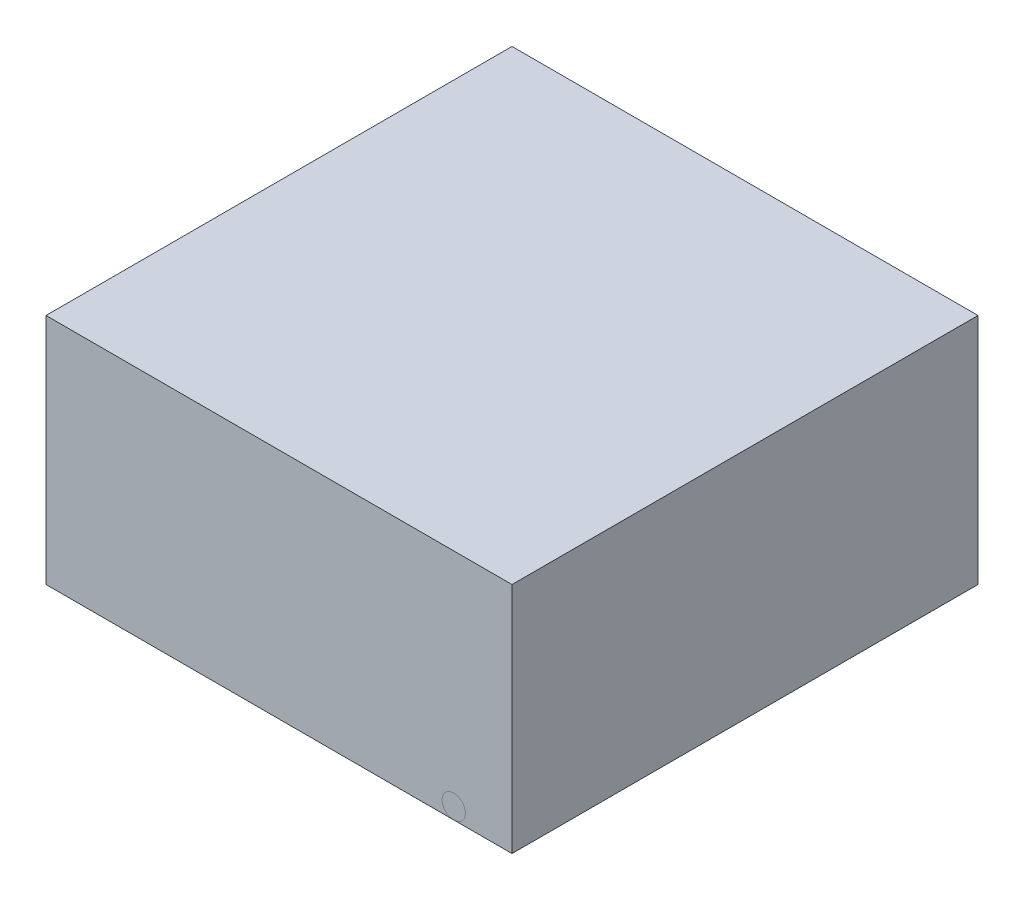
from build123d import *

# Parameters (mm, degrees)
SKETCH1_W           = 20
SKETCH1_H           = 10
BOSS_EXTRUDE1_DEPTH = 20
SKETCH2_R           = 0.5
SLICE_2_DEPTH       = 0.3


with BuildPart() as part:
    # Sketch1 → Boss-Extrude1 (new body)
    with BuildSketch(Plane.XY):
        Rectangle(SKETCH1_W, SKETCH1_H)
    extrude(amount=BOSS_EXTRUDE1_DEPTH)


with BuildPart() as body_2:
    # ag/agcl electrodes: sweep along a path in Sketch3
    with BuildLine(Plane(origin=(7.5, 0, 0), x_dir=(0, 0, -1), z_dir=(1, 0, 0))) as ag_agcl_electrodes_path:
        Line((-20, -4.5), (-5, -4.5))
        ThreePointArc((-5, -4.5), (-4.292893219, -4.207106781), (-4, -3.5))
        Line((-4, -3.5), (-4, 5))
    # Sketch2 → ag/agcl electrodes (sweep)
    with BuildSketch(Plane.XY.offset(20)):
        with Locations((-7.5, -4.5)):
            Circle(SKETCH2_R)
        with Locations((7.5, -4.5)):
            Circle(SKETCH2_R)
    sweep(path=ag_agcl_electrodes_path.line)


with BuildPart() as body_3:
    # Sketch4 → slice 2 (new body)
    with BuildSketch(Plane(origin=(0, -5, 0), x_dir=(1, 0, 0), z_dir=(0, 1, 0))):
        with BuildLine():
            add(Edge.make_bspline(
                [(-1.329786825, -12.04709664), (-1.196342031, -11.939424685), (-0.824147777, -11.548957834), (0.251281573, -11.322574475), (1.372606671, -11.746573561), (2.652909809, -13.571837262), (0.780549472, -13.104467787), (-0.122057097, -13.506347246), (-0.994791107, -13.460960152), (-1.586432094, -13.116889112), (-2.086144249, -12.539169772), (-1.569499382, -12.240512354), (-1.329786825, -12.04709664)],
                knots=[0, 0, 0, 0, 0.049562645, 0.182817887, 0.303261475, 0.461561344, 0.613381106, 0.684437877, 0.79516613, 0.866564728, 0.910968514, 1, 1, 1, 1], degree=3))
        make_face()
    extrude(amount=SLICE_2_DEPTH)


solid = Compound([part.part, body_2.part, body_3.part])
